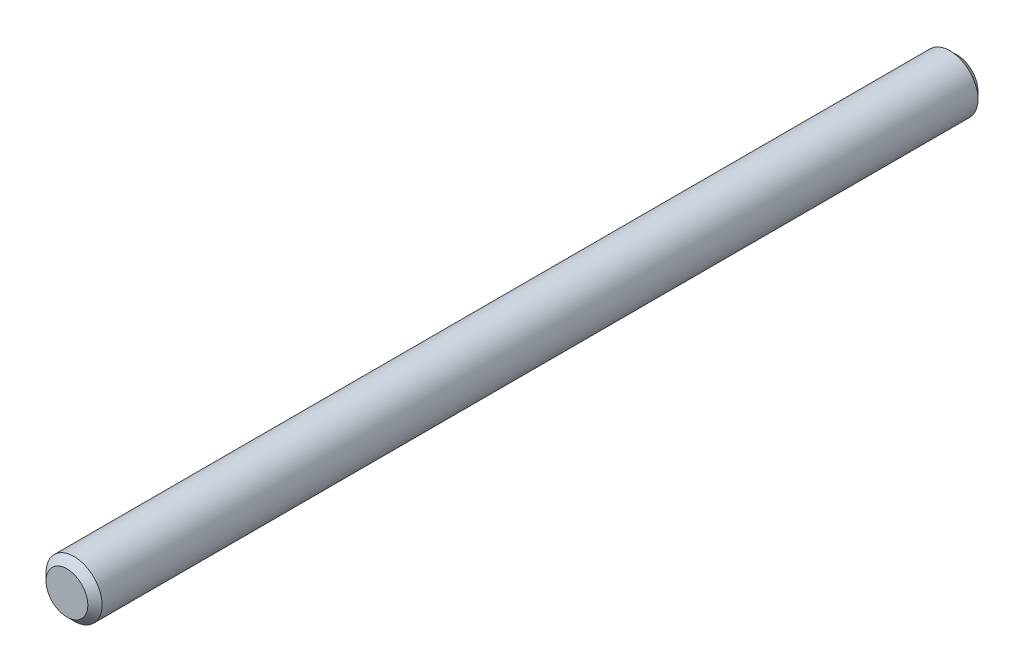
from build123d import *

# Parameters (mm, degrees)
SKETCH1_R           = 2
BOSS_EXTRUDE1_DEPTH = 63.5
CHAMFER1_SIZE       = 0.508


with BuildPart() as part:
    # Sketch1 → Boss-Extrude1 (new body)
    with BuildSketch(Plane.XY):
        Circle(SKETCH1_R)
    extrude(amount=BOSS_EXTRUDE1_DEPTH)

    # Chamfer1
    chamfer1_edges = [part.edges().sort_by_distance(p)[0] for p in [
        (-2, 0, 0),
        (-2, 0, 63.5),
    ]]
    chamfer(chamfer1_edges, length=CHAMFER1_SIZE)


solid = part.part
